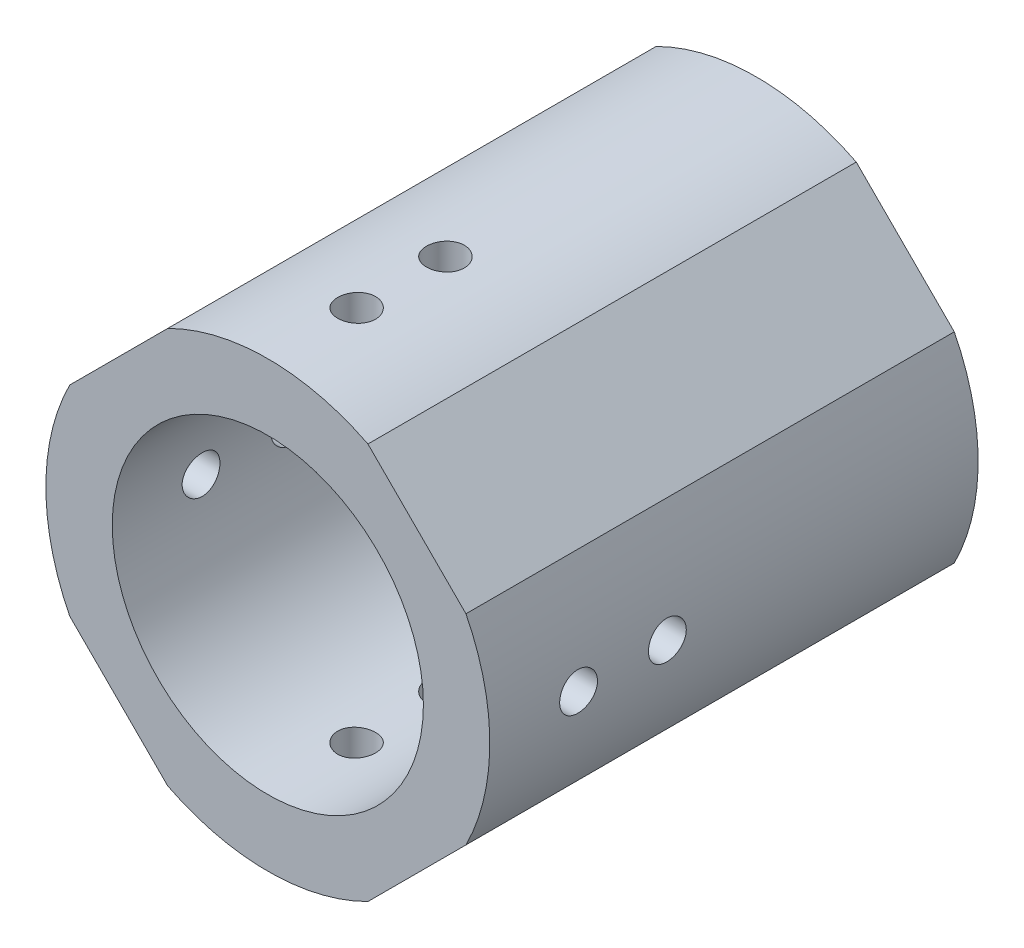
from build123d import *

# Parameters (mm, degrees)
SKETCH2_OUTSIDE_W          = 45.126
SKETCH2_OUTSIDE_H          = 45.126
CUT_EXTRUDE1_DEPTH         = 42.518512437
F_6_32_TAPPED_HOLE1_REACH  = 46.547
F_6_32_TAPPED_HOLE1_BORE_R = 1.35255
CIRPATTERN1_COUNT          = 4
F_7_8_14_TAPPED_HOLE1_D    = 20.6375


with BuildPart() as part:
    # Sketch1 → Revolve1 (revolve)
    with BuildSketch(Plane(origin=(0, 0, 0), x_dir=(0, 0, -1), z_dir=(1, 0, 0)), mode=Mode.PRIVATE) as revolve1_sk:
        with BuildLine():
            Line((-26.913863801, 11.1252), (-5.450863801, 11.1252))
            ThreePointArc((-5.450863801, 11.1252), (-4.180863801, 12.3952), (-2.910863801, 11.1252))
            Line((-2.910863801, 11.1252), (-2.910863801, 9.9695))
            Line((-2.910863801, 9.9695), (8.011136199, 9.9695))
            Line((8.011136199, 9.9695), (8.011136199, 15.875))
            Line((8.011136199, 15.875), (-26.913863801, 15.875))
            Line((-26.913863801, 15.875), (-26.913863801, 11.1252))
        make_face()
    revolve(revolve1_sk.sketch.rotate(Axis((0, 0, 0), (0, 0, 1)), 90), axis=Axis((0, 0, 0), (0, 0, 1)))

    # Sketch2 outside → Cut-Extrude1 (cut, through all)
    with BuildSketch(Plane.XY.offset(26.913863801)):
        Rectangle(SKETCH2_OUTSIDE_W, SKETCH2_OUTSIDE_H)
        Polygon((0, -21.328108288), (-21.328108288, 0), (0, 21.328108288), (21.328108288, 0), align=None, mode=Mode.SUBTRACT)
    extrude(amount=-CUT_EXTRUDE1_DEPTH, mode=Mode.SUBTRACT)

    # 6-32 Tapped Hole1 bore → 6-32 Tapped Hole1 (cut, up to next)
    with BuildSketch(Plane(origin=(15.875, 0, 0), x_dir=(0, 0, -1), z_dir=(1, 0, 0)), mode=Mode.PRIVATE) as f_6_32_tapped_hole1_sk1:
        with Locations((-20.563863801, 0)):
            Circle(F_6_32_TAPPED_HOLE1_BORE_R)
    f_6_32_tapped_hole1_tool1 = extrude(f_6_32_tapped_hole1_sk1.sketch, amount=-F_6_32_TAPPED_HOLE1_REACH, mode=Mode.PRIVATE) & part.part
    # 6-32 Tapped Hole1 bore → 6-32 Tapped Hole1 (cut, up to next)
    with BuildSketch(Plane(origin=(15.875, 0, 0), x_dir=(0, 0, -1), z_dir=(1, 0, 0)), mode=Mode.PRIVATE) as f_6_32_tapped_hole1_sk2:
        with Locations((-14.213863801, 0)):
            Circle(F_6_32_TAPPED_HOLE1_BORE_R)
    f_6_32_tapped_hole1_tool2 = extrude(f_6_32_tapped_hole1_sk2.sketch, amount=-F_6_32_TAPPED_HOLE1_REACH, mode=Mode.PRIVATE) & part.part
    f_6_32_tapped_hole1_1 = f_6_32_tapped_hole1_tool1.solids().sort_by_distance((15.875, 0, 20.563864))[0]
    add(f_6_32_tapped_hole1_1, mode=Mode.SUBTRACT)
    f_6_32_tapped_hole1_2 = f_6_32_tapped_hole1_tool2.solids().sort_by_distance((15.875, 0, 14.213864))[0]
    add(f_6_32_tapped_hole1_2, mode=Mode.SUBTRACT)
    f_6_32_tapped_hole1 = f_6_32_tapped_hole1_1 + f_6_32_tapped_hole1_2  # 6-32 Tapped Hole1 as one shape, for the pattern or mirror that repeats it

    # CirPattern1: 6-32 Tapped Hole1 ×4 about axis
    cirpattern1_axis = Axis((0, 0, 0), (0, 0, -1))
    for i in range(1, CIRPATTERN1_COUNT):
        add(f_6_32_tapped_hole1.rotate(cirpattern1_axis, i * 360 / CIRPATTERN1_COUNT), mode=Mode.SUBTRACT)

    # 7_8-14 Tapped Hole1 (through all)
    with Locations(Plane(origin=(0, 0, -8.011136199), x_dir=(-1, 0, 0), z_dir=(0, 0, -1))):
        with Locations((0, 0)):
            Hole(F_7_8_14_TAPPED_HOLE1_D / 2)


solid = part.part
